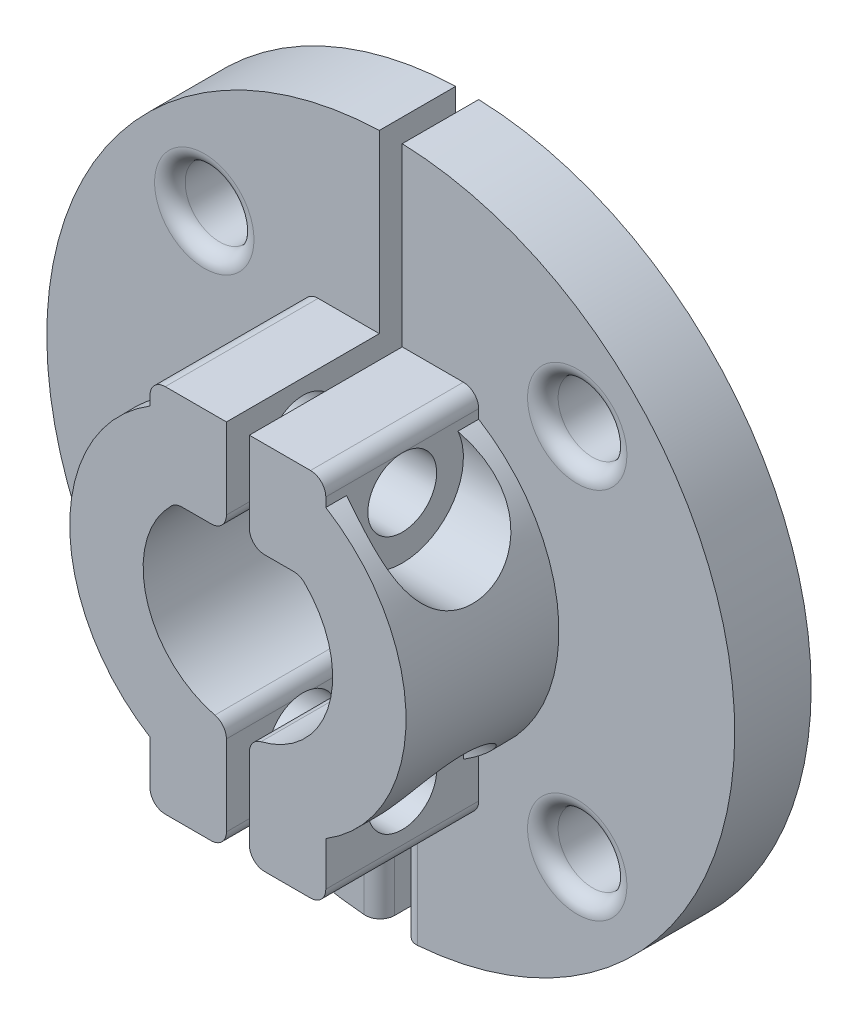
from build123d import *

# Parameters (mm, degrees)
SKETCH1_R               = 22.5
SKETCH1_R_2             = 6.2
SKETCH1_R_3             = 2.25
BOSS_EXTRUDE1_DEPTH     = 15
SKETCH2_OUTSIDE_W       = 60.076
SKETCH2_OUTSIDE_H       = 60.076
SKETCH2_OUTSIDE_R       = 11
CUT_EXTRUDE1_DEPTH      = 10
SKETCH4_W               = 1.5
SKETCH4_H               = 48.13303
CUT_EXTRUDE2_DEPTH      = 34.35416
CUT_EXTRUDE2_DEPTH_BACK = 34.35416
BOSS_EXTRUDE7_DEPTH     = 15
SKETCH16_W              = 5
SKETCH16_H              = 5
BOSS_EXTRUDE9_DEPTH     = 10
FILLET1_R               = 1
FILLET2_R               = 1
FILLET14_R              = 1
FILLET19_R              = 1
FILLET20_R              = 1
FILLET21_R              = 1
FILLET22_R              = 1
FILLET25_R              = 1
FILLET26_R              = 1
FILLET27_R              = 1
FILLET33_R              = 1
FILLET35_R              = 1
FILLET36_R              = 1
FILLET37_R              = 1
SKETCH17_R              = 2.25
CUT_EXTRUDE3_DEPTH      = 40.099233
CUT_EXTRUDE3_DEPTH_BACK = 40.099233
SKETCH20_R              = 4
CUT_EXTRUDE9_DEPTH      = 40.099233
SKETCH21_R              = 4
CUT_EXTRUDE10_DEPTH     = 40.099233
FILLET38_R              = 1
FILLET39_R              = 1


with BuildPart() as part:
    # Sketch1 → Boss-Extrude1 (new body)
    with BuildSketch(Plane.XY):
        Circle(SKETCH1_R)
        Circle(SKETCH1_R_2, mode=Mode.SUBTRACT)
        with Locations((12.197592, 12.197592)):
            Circle(SKETCH1_R_3, mode=Mode.SUBTRACT)
        with Locations(Location((-12.197592, 12.197592, 0), (0, 0, 180))):
            Circle(SKETCH1_R_3, mode=Mode.SUBTRACT)
        with Locations(Location((12.197592, -12.197592, 0), (0, 0, 180))):
            Circle(SKETCH1_R_3, mode=Mode.SUBTRACT)
        with Locations((-12.197592, -12.197592)):
            Circle(SKETCH1_R_3, mode=Mode.SUBTRACT)
    extrude(amount=BOSS_EXTRUDE1_DEPTH)

    # Sketch2 outside → Cut-Extrude1 (cut)
    with BuildSketch(Plane.XY.offset(15)):
        Rectangle(SKETCH2_OUTSIDE_W, SKETCH2_OUTSIDE_H)
        Circle(SKETCH2_OUTSIDE_R, mode=Mode.SUBTRACT)
    extrude(amount=-CUT_EXTRUDE1_DEPTH, mode=Mode.SUBTRACT)

    # Sketch4 → Cut-Extrude2 (cut, two sides)
    with BuildSketch(Plane.XY.offset(5)) as cut_extrude2_sk:
        Rectangle(SKETCH4_W, SKETCH4_H)
    extrude(amount=CUT_EXTRUDE2_DEPTH, mode=Mode.SUBTRACT)
    extrude(cut_extrude2_sk.sketch, amount=-CUT_EXTRUDE2_DEPTH_BACK, mode=Mode.SUBTRACT)


with BuildPart() as cut_extrude2_piece_1:
    # of the separate pieces the step leaves, piece 1, a body of its own (cut_extrude2_pieces)
    add(part.part.solids().sort_by_distance((0.75, 22.487497, 5))[0])



with BuildPart() as cut_extrude2_piece_2:
    # of the separate pieces the step leaves, piece 2, a body of its own (cut_extrude2_pieces)
    add(part.part.solids().sort_by_distance((-0.75, 22.487497, 0))[0])


with BuildPart() as cut_extrude2_piece_1_1:
    add(cut_extrude2_piece_1.part)

    add(cut_extrude2_piece_2.part)  # Boss-Extrude7 merges Cut-Extrude2 piece 2
    # Sketch9 → Boss-Extrude7 (add)
    with BuildSketch(Plane(origin=(0, 0, 0), x_dir=(-1, 0, 0), z_dir=(0, 0, -1))):
        with BuildLine():
            ThreePointArc((-0.75, 6.15447), (-2.504658, 5.671568), (-4.043513, 4.7))
            Line((-4.043513, 4.7), (-0.75, 4.7))
            Line((-0.75, 4.7), (-0.75, 6.15447))
        make_face()
        with BuildLine():
            Line((0.75, 4.7), (4.043513, 4.7))
            ThreePointArc((4.043513, 4.7), (2.504658, 5.671568), (0.75, 6.15447))
            Line((0.75, 6.15447), (0.75, 4.7))
        make_face()
    extrude(amount=-BOSS_EXTRUDE7_DEPTH)

    # Sketch16 → Boss-Extrude9 (add)
    with BuildSketch(Plane.XY.offset(5)):
        Polygon((5.75, 3.475), (5.75, 10), (5.75, 10.974402), (0.75, 10.974402), align=None)
        Polygon((-5.75, 3.475), (-5.75, 10.02714), (-5.75, 10.974402), (-0.75, 10.974402), align=None)
        with Locations((-3.25, -10.749622)):
            Rectangle(SKETCH16_W, SKETCH16_H)
        with Locations((3.25, -10.749622)):
            Rectangle(SKETCH16_W, SKETCH16_H)
    extrude(amount=BOSS_EXTRUDE9_DEPTH)

    # Fillet1
    fillet1_edges = [cut_extrude2_piece_1_1.edges().sort_by_distance(p)[0] for p in [
        (-4.043513, 4.7, 7.5),
    ]]
    fillet(fillet1_edges, radius=FILLET1_R)

    # Fillet2
    fillet2_edges = [cut_extrude2_piece_1_1.edges().sort_by_distance(p)[0] for p in [
        (4.043513, 4.7, 7.5),
    ]]
    fillet(fillet2_edges, radius=FILLET2_R)

    # Fillet14
    fillet14_edges = [cut_extrude2_piece_1_1.edges().sort_by_distance(p)[0] for p in [
        (-0.75, -6.15447, 7.5),
    ]]
    fillet(fillet14_edges, radius=FILLET14_R)

    # Fillet19
    fillet19_edges = [cut_extrude2_piece_1_1.edges().sort_by_distance(p)[0] for p in [
        (-0.75, -13.249622, 10),
    ]]
    fillet(fillet19_edges, radius=FILLET19_R)

    # Fillet20
    fillet20_edges = [cut_extrude2_piece_1_1.edges().sort_by_distance(p)[0] for p in [
        (0.75, -13.249622, 10),
    ]]
    fillet(fillet20_edges, radius=FILLET20_R)

    # Fillet21
    fillet21_edges = [cut_extrude2_piece_1_1.edges().sort_by_distance(p)[0] for p in [
        (-0.75, -17.368559, 5),
    ]]
    fillet(fillet21_edges, radius=FILLET21_R)

    # Fillet22
    fillet22_edges = [cut_extrude2_piece_1_1.edges().sort_by_distance(p)[0] for p in [
        (0.75, -17.368559, 5),
    ]]
    fillet(fillet22_edges, radius=FILLET22_R)

    # Fillet25
    fillet25_edges = [cut_extrude2_piece_1_1.edges().sort_by_distance(p)[0] for p in [
        (-9.947592, 12.197592, 0),
        (-9.947592, 12.197592, 5),
    ]]
    fillet(fillet25_edges, radius=FILLET25_R)

    # Fillet26
    fillet26_edges = [cut_extrude2_piece_1_1.edges().sort_by_distance(p)[0] for p in [
        (9.947592, 12.197592, 5),
        (9.947592, 12.197592, 0),
    ]]
    fillet(fillet26_edges, radius=FILLET26_R)

    # Fillet27
    fillet27_edges = [cut_extrude2_piece_1_1.edges().sort_by_distance(p)[0] for p in [
        (14.447592, -12.197592, 0),
        (14.447592, -12.197592, 5),
    ]]
    fillet(fillet27_edges, radius=FILLET27_R)

    # Fillet33
    fillet33_edges = [cut_extrude2_piece_1_1.edges().sort_by_distance(p)[0] for p in [
        (-14.447592, -12.197592, 0),
        (-14.447592, -12.197592, 5),
    ]]
    fillet(fillet33_edges, radius=FILLET33_R)

    # Fillet35
    fillet35_edges = [cut_extrude2_piece_1_1.edges().sort_by_distance(p)[0] for p in [
        (0.75, -6.15447, 7.5),
    ]]
    fillet(fillet35_edges, radius=FILLET35_R)

    # Fillet36
    fillet36_edges = [cut_extrude2_piece_1_1.edges().sort_by_distance(p)[0] for p in [
        (-0.75, 4.7, 7.5),
    ]]
    fillet(fillet36_edges, radius=FILLET36_R)

    # Fillet37
    fillet37_edges = [cut_extrude2_piece_1_1.edges().sort_by_distance(p)[0] for p in [
        (0.75, 4.7, 7.5),
    ]]
    fillet(fillet37_edges, radius=FILLET37_R)

    # Sketch17 → Cut-Extrude3 (cut, two sides)
    with BuildSketch(Plane.ZY.offset(5.75)) as cut_extrude3_sk:
        with Locations(Location((10, 7.724701, 0), (0, 0, 295.859394))):
            Circle(SKETCH17_R)
        with Locations(Location((10, -9.125, 0), (0, 0, 353.556576))):
            Circle(SKETCH17_R)
    extrude(amount=CUT_EXTRUDE3_DEPTH, mode=Mode.SUBTRACT)
    extrude(cut_extrude3_sk.sketch, amount=-CUT_EXTRUDE3_DEPTH_BACK, mode=Mode.SUBTRACT)

    # Sketch20 → Cut-Extrude9 (cut, through all)
    with BuildSketch(Plane.ZY.offset(5.75)):
        with Locations((10, -9.125)):
            Circle(SKETCH20_R)
        with Locations((10, 7.724701)):
            Circle(SKETCH20_R)
    extrude(amount=CUT_EXTRUDE9_DEPTH, mode=Mode.SUBTRACT)

    # Sketch21 → Cut-Extrude10 (cut, through all)
    with BuildSketch(Plane(origin=(5.75, 0, 0), x_dir=(0, 0, -1), z_dir=(1, 0, 0))):
        with Locations((-10, 7.724701)):
            Circle(SKETCH21_R)
        with Locations((-10, -9.125)):
            Circle(SKETCH21_R)
    extrude(amount=CUT_EXTRUDE10_DEPTH, mode=Mode.SUBTRACT)

    # Fillet38
    fillet38_edges = [cut_extrude2_piece_1_1.edges().sort_by_distance(p)[0] for p in [
        (-5.75, 10.974402, 10),
        (-5.75, -13.249622, 10),
    ]]
    fillet(fillet38_edges, radius=FILLET38_R)

    # Fillet39
    fillet39_edges = [cut_extrude2_piece_1_1.edges().sort_by_distance(p)[0] for p in [
        (5.75, 10.974402, 10),
        (5.75, -13.249622, 10),
    ]]
    fillet(fillet39_edges, radius=FILLET39_R)


solid = cut_extrude2_piece_1_1.part
